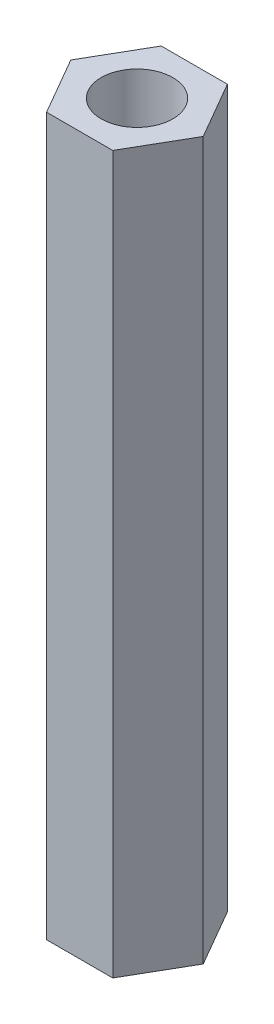
from build123d import *

# Parameters (mm, degrees)
SKETCH1_R           = 2.5
BOSS_EXTRUDE1_DEPTH = 50


with BuildPart() as part:
    # Sketch1 → Boss-Extrude1 (new body)
    with BuildSketch(Plane(origin=(0, 0, 0), x_dir=(1, 0, 0), z_dir=(0, 1, 0))):
        Polygon((4.618802154, 0), (2.309401077, 4), (-2.309401077, 4), (-4.618802154, 0), (-2.309401077, -4), (2.309401077, -4), align=None)
        Circle(SKETCH1_R, mode=Mode.SUBTRACT)
    extrude(amount=BOSS_EXTRUDE1_DEPTH)


solid = part.part
